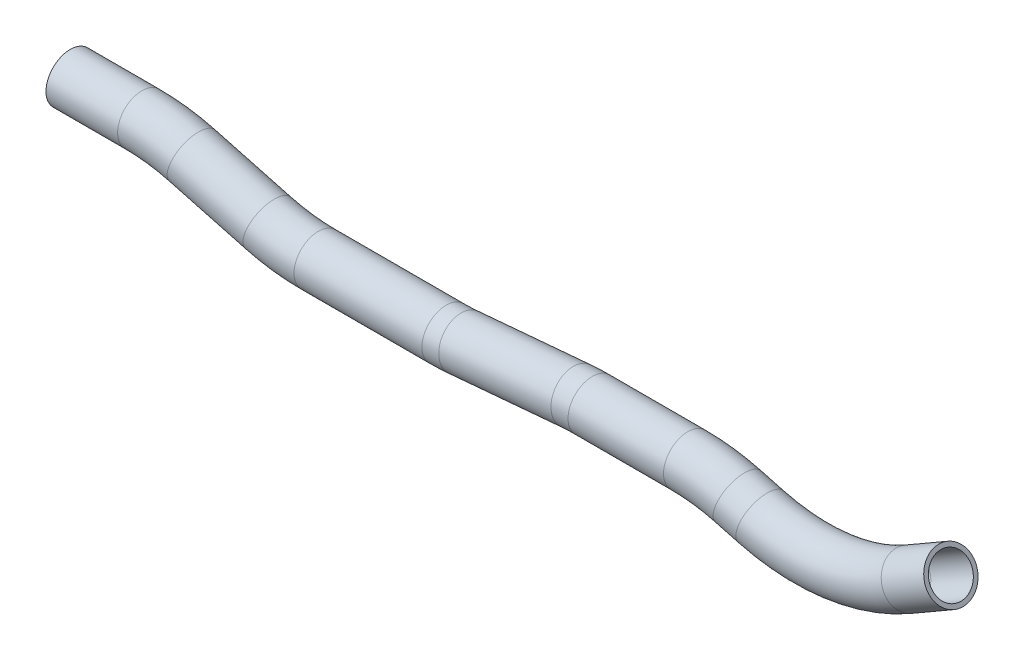
from build123d import *

# Parameters (mm, degrees)
SKETCH2_R   = 9.525
SKETCH2_R_2 = 7.874


with BuildPart() as part:
    # Sweep1: sweep along a path in Sketch1
    with BuildLine(Plane.XY) as sweep1_path:
        Line((124.181687085, -15.949323606), (152.249766769, -15.949323606))
        ThreePointArc((152.249766769, -15.949323606), (162.195862616, -16.601225169), (171.971778005, -18.545775643))
        Line((171.971778005, -18.545775643), (201.66062814, -26.50087906))
        ThreePointArc((201.66062814, -26.50087906), (211.436543529, -28.445429534), (221.382639376, -29.097331097))
        Line((221.382639376, -29.097331097), (271.523755211, -29.097331097))
        ThreePointArc((271.523755211, -29.097331097), (274.847552528, -29.024805582), (278.165022808, -28.807367092))
        Line((278.165022808, -28.807367092), (322.143105976, -24.959783371))
        ThreePointArc((322.143105976, -24.959783371), (325.460576256, -24.742344881), (328.784373573, -24.669819366))
        Line((328.784373573, -24.669819366), (366.225489407, -24.669819366))
        ThreePointArc((366.225489407, -24.669819366), (376.171585254, -25.321720929), (385.947500644, -27.266271402))
        Line((385.947500644, -27.266271402), (394.838853894, -29.648702325))
        ThreePointArc((394.838853894, -29.648702325), (424.506960978, -31.593252799), (452.66086513, -22.03629013))
        Line((452.66086513, -22.03629013), (469.320532211, -12.417826857))
    # Sketch2 → Sweep1 (sweep)
    with BuildSketch(Plane(origin=(124.181687085, -15.949323606, 0), x_dir=(0, 0, -1), z_dir=(1, 0, 0))):
        Circle(SKETCH2_R)
        Circle(SKETCH2_R_2, mode=Mode.SUBTRACT)
    sweep(path=sweep1_path.line)


solid = part.part
